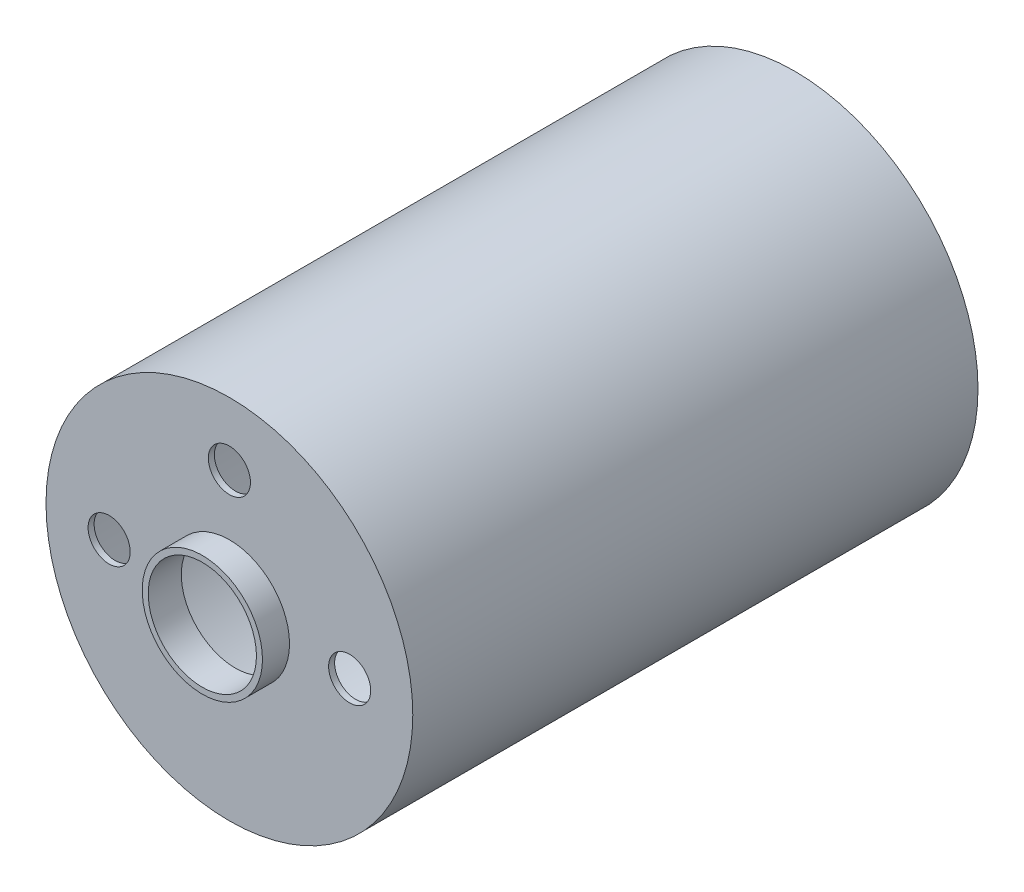
from build123d import *

# Parameters (mm, degrees)
SKETCH1_R           = 15.25
BOSS_EXTRUDE1_DEPTH = 23.5
SKETCH2_R           = 5
BOSS_EXTRUDE2_DEPTH = 2.25
SHELL1_T            = -0.5
SKETCH3_R           = 1.75
CUT_EXTRUDE1_DEPTH  = 4.5


with BuildPart() as part:
    # Sketch1 → Boss-Extrude1 (new, symmetric)
    with BuildSketch(Plane.XY):
        Circle(SKETCH1_R)
    extrude(amount=BOSS_EXTRUDE1_DEPTH, both=True)

    # Sketch2 → Boss-Extrude2 (add, symmetric)
    with BuildSketch(Plane.XY.offset(23.5)):
        Circle(SKETCH2_R)
    extrude(amount=BOSS_EXTRUDE2_DEPTH, both=True)

    # Shell1
    shell1_openings = [part.faces().sort_by_distance(p)[0] for p in [
        (0, 0, -23.5),
        (0, 0, 25.75),
    ]]
    offset(amount=SHELL1_T, openings=shell1_openings, kind=Kind.INTERSECTION)

    # Sketch3 → Cut-Extrude1 (cut)
    with BuildSketch(Plane.XY.offset(23.5)):
        with Locations((-10, 0)):
            Circle(SKETCH3_R)
        with Locations((0, 10)):
            Circle(SKETCH3_R)
        with Locations((10, 0)):
            Circle(SKETCH3_R)
    extrude(amount=-CUT_EXTRUDE1_DEPTH, mode=Mode.SUBTRACT)


solid = part.part
